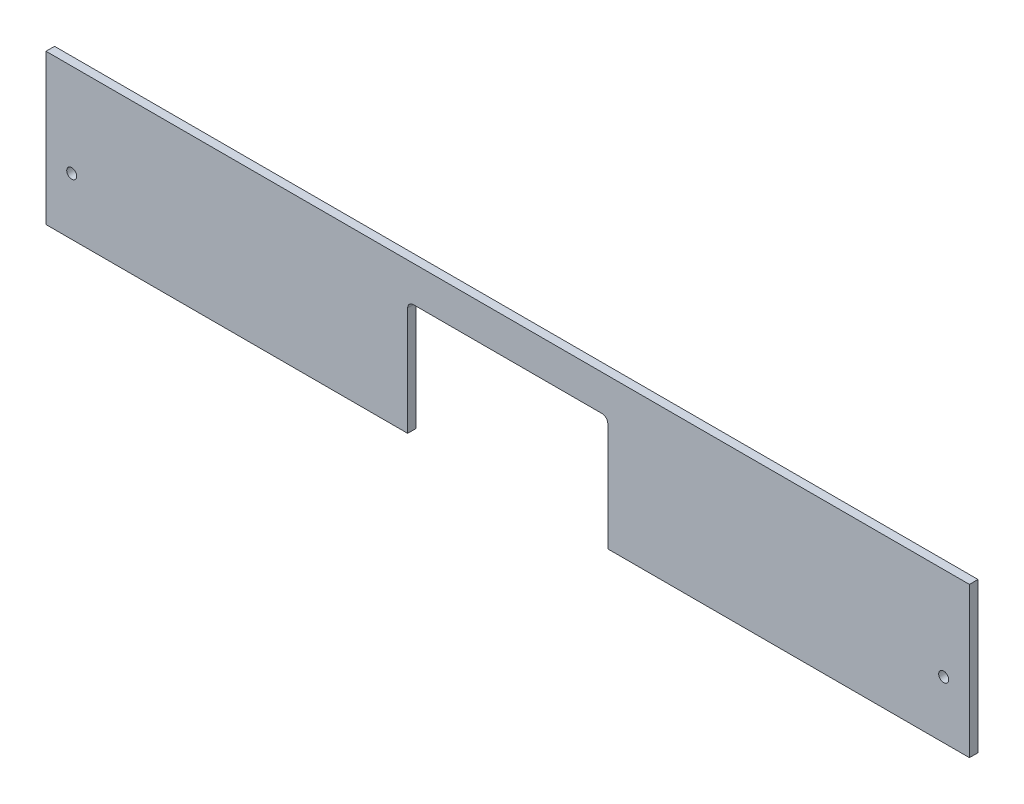
from build123d import *

# Parameters (mm, degrees)
SKETCH1_W               = 323
SKETCH1_H               = 50
BOSS_EXTRUDE1_DEPTH     = 3
SKETCH2_W               = 70
SKETCH2_H               = 40
CUT_EXTRUDE1_DEPTH      = 1
CUT_EXTRUDE1_DEPTH_BACK = 4
FILLET1_R               = 2
SKETCH3_W               = 323
SKETCH3_H               = 3
BOSS_EXTRUDE2_DEPTH     = 2.5
SKETCH4_R               = 1.75
CUT_EXTRUDE2_DEPTH      = 4


with BuildPart() as part:
    # Sketch1 → Boss-Extrude1 (new body)
    with BuildSketch(Plane.XY):
        Rectangle(SKETCH1_W, SKETCH1_H)
    extrude(amount=BOSS_EXTRUDE1_DEPTH)

    # Sketch2 → Cut-Extrude1 (cut, two sides)
    with BuildSketch(Plane.XY.offset(3)) as cut_extrude1_sk:
        with Locations((0, -5)):
            Rectangle(SKETCH2_W, SKETCH2_H)
    extrude(amount=CUT_EXTRUDE1_DEPTH, mode=Mode.SUBTRACT)
    extrude(cut_extrude1_sk.sketch, amount=-CUT_EXTRUDE1_DEPTH_BACK, mode=Mode.SUBTRACT)

    # Fillet1
    fillet1_edges = [part.edges().sort_by_distance(p)[0] for p in [
        (-35, 15, 1.5),
        (35, 15, 1.5),
    ]]
    fillet(fillet1_edges, radius=FILLET1_R)

    # Sketch3 → Boss-Extrude2 (add)
    with BuildSketch(Plane(origin=(0, 25, 0), x_dir=(1, 0, 0), z_dir=(0, 1, 0))):
        with Locations((0, -1.5)):
            Rectangle(SKETCH3_W, SKETCH3_H)
    extrude(amount=BOSS_EXTRUDE2_DEPTH)

    # Sketch4 → Cut-Extrude2 (cut, through all)
    with BuildSketch(Plane.XY.offset(3)):
        with Locations((-152.5, -5)):
            Circle(SKETCH4_R)
        with Locations(Location((152.5, -5, 0), (0, 0, 180))):  # turned: the seam where the file's is
            Circle(SKETCH4_R)
    extrude(amount=-CUT_EXTRUDE2_DEPTH, mode=Mode.SUBTRACT)


solid = part.part
